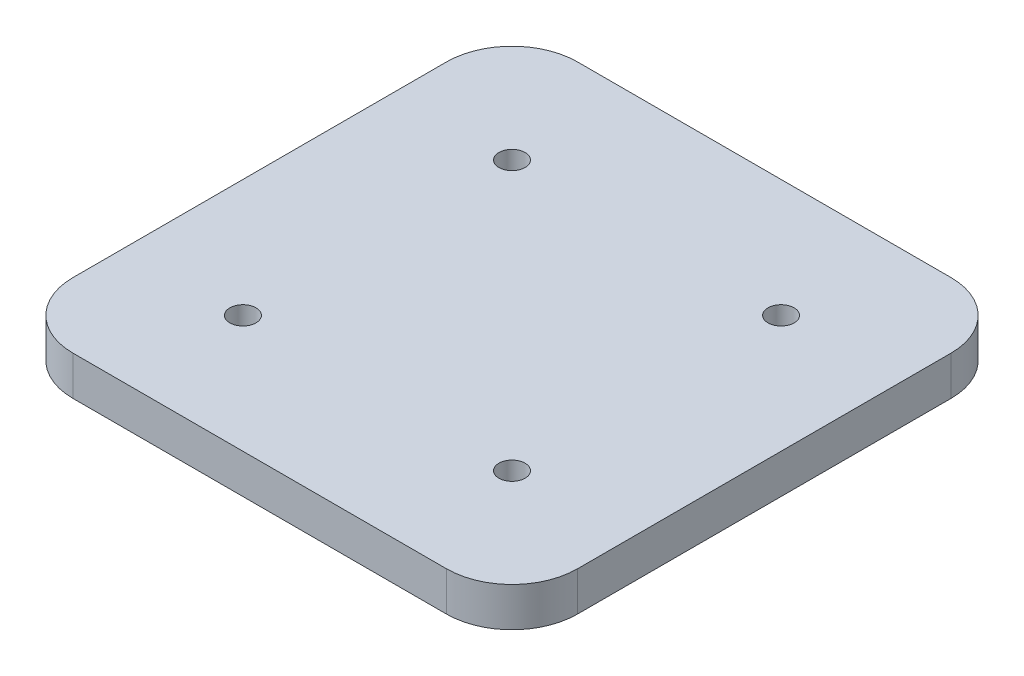
from build123d import *

# Parameters (mm, degrees)
CROQUIS1_W              = 77.15
CROQUIS1_H              = 77.15
SALIENTE_EXTRUIR1_DEPTH = 6
CROQUIS2_R              = 2
CORTAR_EXTRUIR1_DEPTH   = 40
REDONDEO1_R             = 10


with BuildPart() as part:
    # Croquis1 → Saliente-Extruir1 (new body)
    with BuildSketch(Plane.XZ.offset(-65.5)):
        with Locations((63.993998695, -38.595)):
            Rectangle(CROQUIS1_W, CROQUIS1_H)
    extrude(amount=-SALIENTE_EXTRUIR1_DEPTH)

    # Croquis2 → Cortar-Extruir1 (cut)
    with BuildSketch(Plane(origin=(0, 71.5, 0), x_dir=(1, 0, 0), z_dir=(0, 1, 0))):
        with Locations((84.568998695, 59.17)):
            Circle(CROQUIS2_R)
        with Locations((84.568998695, 18.02)):
            Circle(CROQUIS2_R)
        with Locations((43.418998695, 18.02)):
            Circle(CROQUIS2_R)
        with Locations((43.418998695, 59.17)):
            Circle(CROQUIS2_R)
    extrude(amount=-CORTAR_EXTRUIR1_DEPTH, mode=Mode.SUBTRACT)

    # Redondeo1
    redondeo1_edges = [part.edges().sort_by_distance(p)[0] for p in [
        (25.418998695, 68.5, -0.02),
        (102.568998695, 68.5, -0.02),
        (102.568998695, 68.5, -77.17),
        (25.418998695, 68.5, -77.17),
    ]]
    fillet(redondeo1_edges, radius=REDONDEO1_R)


solid = part.part
